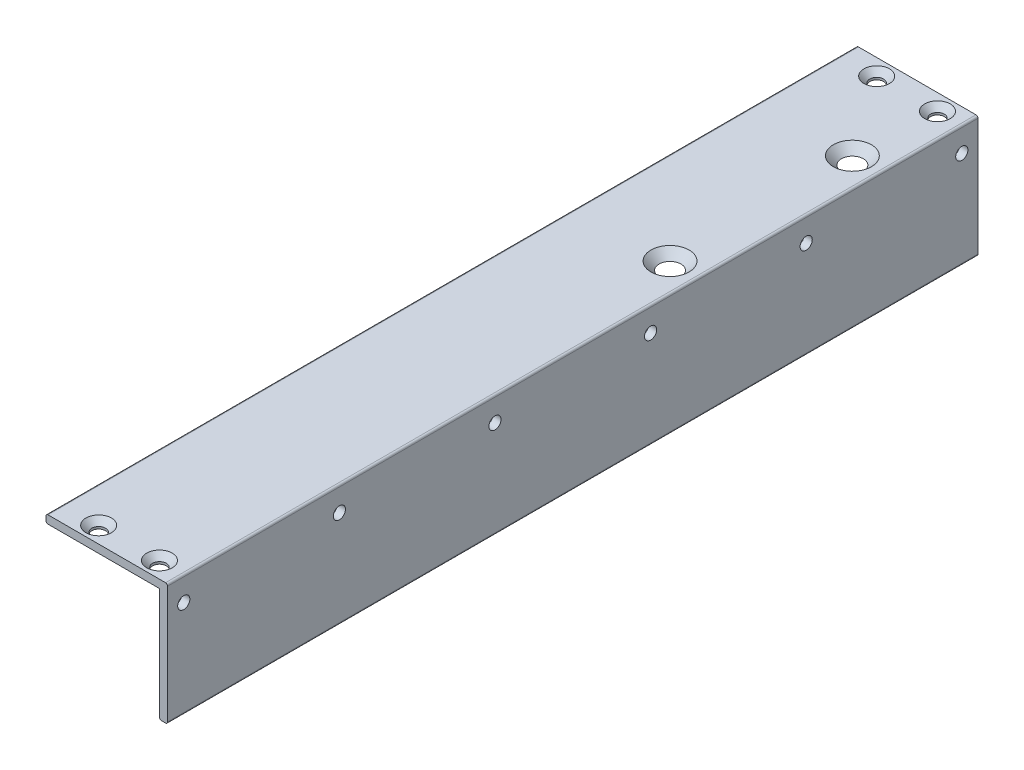
from build123d import *

# Parameters (mm, degrees)
EXTRUDE1_DEPTH                               = 200
FILLET1_R                                    = 0.5
CSK_FOR_M4_COUNTERSUNK_FLAT_HEAD_SCR_2_COUNT = 2
CSK_FOR_M4_COUNTERSUNK_FLAT_HEAD_SCR_2_PITCH = 45
CSK_FOR_M3_COUNTERSUNK_FLAT_HEAD_SCR_2_COUNT = 2
CSK_FOR_M3_COUNTERSUNK_FLAT_HEAD_SCR_2_PITCH = 15
CSK_FOR_M3_COUNTERSUNK_FLAT_HEAD_SCR_3_COUNT = 2
CSK_FOR_M3_COUNTERSUNK_FLAT_HEAD_SCR_3_PITCH = 15
M3_TAPPED_HOLE1_D                            = 3
M3_TAPPED_HOLE1_DEPTH                        = 2.001
LPATTERN1_COUNT                              = 6
LPATTERN1_PITCH                              = 38.4


with BuildPart() as part:
    # Sketch1 → Extrude1 (new body)
    with BuildSketch(Plane.XY):
        Polygon((0, 0), (0, 28), (-28, 28), (-28, 30), (2, 30), (2, 0), align=None)
    extrude(amount=EXTRUDE1_DEPTH)

    # Fillet1
    fillet1_edges = [part.edges().sort_by_distance(p)[0] for p in [
        (-28, 28, 100),
        (-28, 30, 100),
        (2, 30, 100),
        (2, 0, 100),
        (0, 0, 100),
    ]]
    fillet(fillet1_edges, radius=FILLET1_R)

    # Sketch4 → CSK for M4 Countersunk Flat Head Screw1 (revolve, cut)
    with BuildSketch(Plane(origin=(-5, 30, 69), x_dir=(0, 0, 1), z_dir=(1, 0, 0))):
        Polygon((0, 0), (0, 2), (2.25, 2), (2.25, 2.45), (4.7, 0), align=None)
    csk_for_m4_countersunk_flat_head_screw1 = revolve(axis=Axis((-5, 36.35, 69), (0, -1, 0)), mode=Mode.SUBTRACT)

    # CSK for M4 Countersunk Flat Head Scr 2: CSK for M4 Countersunk Flat Head Screw1 ×2
    with Locations(*[(0, 0, -i * CSK_FOR_M4_COUNTERSUNK_FLAT_HEAD_SCR_2_PITCH) for i in range(1, CSK_FOR_M4_COUNTERSUNK_FLAT_HEAD_SCR_2_COUNT)]):
        add(csk_for_m4_countersunk_flat_head_screw1, mode=Mode.SUBTRACT)

    # Sketch5 → CSK for M3 Countersunk Flat Head Screw1 (revolve, cut)
    with BuildSketch(Plane(origin=(-19, 30, 4), x_dir=(0, 0, 1), z_dir=(1, 0, 0))):
        Polygon((0, 0), (0, 2), (1.7, 2), (1.7, 1.45), (3.15, 0), align=None)
    csk_for_m3_countersunk_flat_head_screw1 = revolve(axis=Axis((-19, 36.35, 4), (0, -1, 0)), mode=Mode.SUBTRACT)

    # CSK for M3 Countersunk Flat Head Scr 2: CSK for M3 Countersunk Flat Head Screw1 ×2
    with Locations(*[(i * CSK_FOR_M3_COUNTERSUNK_FLAT_HEAD_SCR_2_PITCH, 0, 0) for i in range(1, CSK_FOR_M3_COUNTERSUNK_FLAT_HEAD_SCR_2_COUNT)]):
        add(csk_for_m3_countersunk_flat_head_screw1, mode=Mode.SUBTRACT)

    # Sketch6 → CSK for M3 Countersunk Flat Head Screw2 (revolve, cut)
    with BuildSketch(Plane(origin=(-19, 30, 196), x_dir=(0, 0, 1), z_dir=(1, 0, 0))):
        Polygon((0, 0), (0, 2), (1.7, 2), (1.7, 1.45), (3.15, 0), align=None)
    csk_for_m3_countersunk_flat_head_screw2 = revolve(axis=Axis((-19, 36.35, 196), (0, -1, 0)), mode=Mode.SUBTRACT)

    # CSK for M3 Countersunk Flat Head Scr 3: CSK for M3 Countersunk Flat Head Screw2 ×2
    with Locations(*[(i * CSK_FOR_M3_COUNTERSUNK_FLAT_HEAD_SCR_3_PITCH, 0, 0) for i in range(1, CSK_FOR_M3_COUNTERSUNK_FLAT_HEAD_SCR_3_COUNT)]):
        add(csk_for_m3_countersunk_flat_head_screw2, mode=Mode.SUBTRACT)

    # M3 Tapped Hole1
    with Locations(Plane(origin=(2, 24, 4), x_dir=(0, 1, 0), z_dir=(1, 0, 0))):
        with Locations((0, 0)):
            m3_tapped_hole1 = Hole(M3_TAPPED_HOLE1_D / 2, depth=M3_TAPPED_HOLE1_DEPTH)

    # LPattern1: M3 Tapped Hole1 ×6
    with Locations(*[(0, 0, i * LPATTERN1_PITCH) for i in range(1, LPATTERN1_COUNT)]):
        add(m3_tapped_hole1, mode=Mode.SUBTRACT)


solid = part.part
